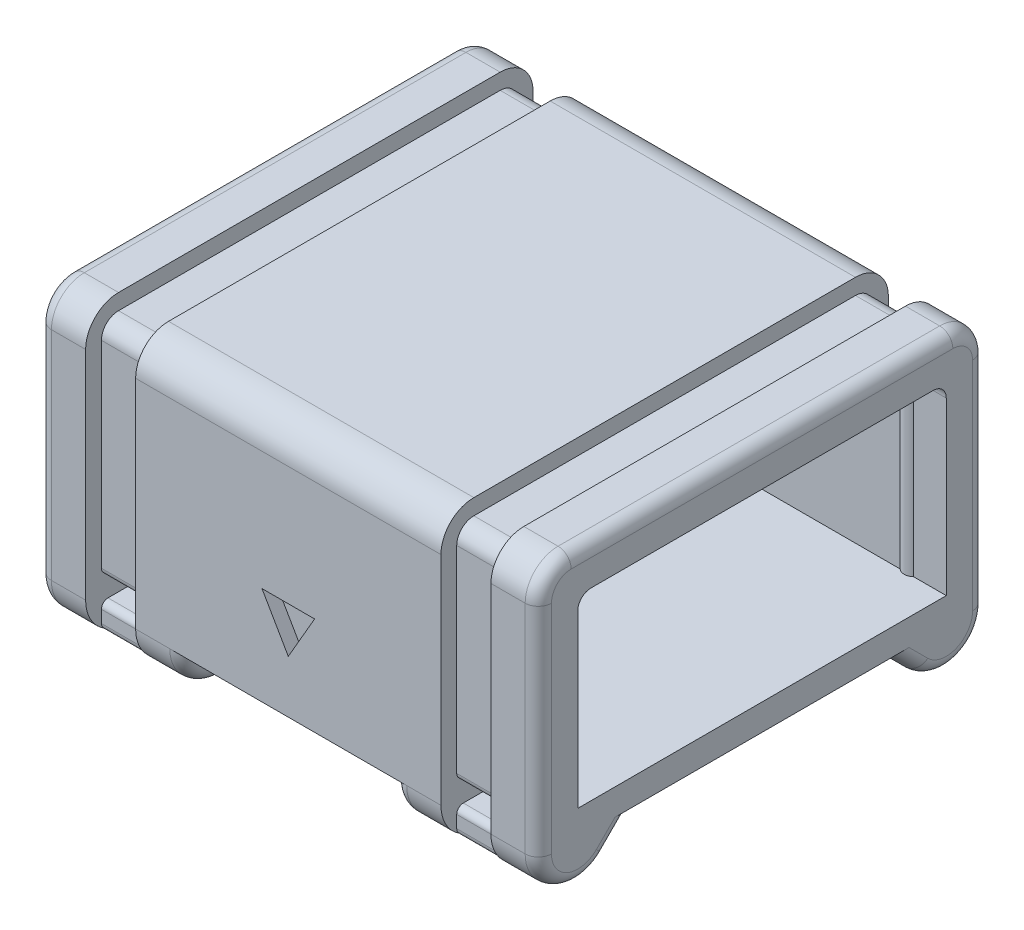
from build123d import *

# Parameters (mm, degrees)
AUFSATZ_LINEAR_AUSTRAGEN2_DEPTH           = 19
SCHNITT_LINEAR_AUSTRAGEN3_DEPTH           = 17
AUFSATZ_LINEAR_AUSTRAGEN9_DEPTH           = 38
SKIZZE14_W                                = 28
SKIZZE14_H                                = 9
AUFSATZ_LINEAR_AUSTRAGEN8_DEPTH           = 2
SCHNITT_LINEAR_AUSTRAGEN5_DEPTH           = 2
AUFSATZ_LINEAR_AUSTRAGEN10_DEPTH          = 14
SKIZZE20_R                                = 1.5
SCHNITT_LINEAR_AUSTRAGEN7_DEPTH           = 37.0000001
SCHNITT_LINEAR_AUSTRAGEN7_DEPTH_BACK      = 3
LINEARES_MUSTER1_COUNT                    = 2
LINEARES_MUSTER1_PITCH                    = 24
SKIZZE21_W                                = 16
SKIZZE21_H                                = 3
SCHNITT_LINEAR_AUSTRAGEN9_DEPTH           = 18
SCHNITT_LINEAR_AUSTRAGEN9_DEPTH_BACK      = 18
SKIZZE10_W                                = 10
SKIZZE10_H                                = 1.5
SKIZZE10_W_2                              = 7
SCHNITT_LINEAR_AUSTRAGEN8_DEPTH           = 1
SCHNITT_LINEAR_AUSTRAGEN10_DEPTH          = 1
SCHNITT_LINEAR_AUSTRAGEN11_DEPTH          = 1
VERRUNDUNG1_R                             = 1
VERRUNDUNG4_R                             = 1
SCHNITT_LINEAR_AUSTRAGEN_D_NN1_DEPTH      = 1.9
SCHNITT_LINEAR_AUSTRAGEN_D_NN1_DEPTH_BACK = 1.9
SCHNITT_LINEAR_AUSTRAGEN_D_NN2_DEPTH      = 1.9
SCHNITT_LINEAR_AUSTRAGEN_D_NN2_DEPTH_BACK = 1.9
SKIZZE26_W                                = 2
SKIZZE26_H                                = 8.3
AUFSATZ_LINEAR_AUSTRAGEN11_DEPTH          = 2
SKIZZE27_W                                = 3.8
SKIZZE27_H                                = 1.7
SCHNITT_LINEAR_AUSTRAGEN13_DEPTH          = 18
SCHNITT_LINEAR_AUSTRAGEN13_DEPTH_BACK     = 18.0000001
VERRUNDUNG5_R                             = 0.5
SCHNITT_LINEAR_AUSTRAGEN14_DEPTH          = 1


with BuildPart() as part:
    # Skizze2 → Aufsatz-Linear austragen2 (new body, symmetric)
    with BuildSketch(Plane(origin=(0, 0, 0), x_dir=(0, 0, -1), z_dir=(1, 0, 0))):
        with BuildLine():
            Line((-14, 9), (14, 9))
            Line((14, 9), (14, 0))
            Line((14, 0), (17, 0))
            Line((17, 0), (17, 14.5))
            ThreePointArc((17, 14.5), (16.267766953, 16.267766953), (14.5, 17))
            Line((14.5, 17), (-14.5, 17))
            ThreePointArc((-14.5, 17), (-16.267766953, 16.267766953), (-17, 14.5))
            Line((-17, 14.5), (-17, 0))
            Line((-17, 0), (-14, 0))
            Line((-14, 0), (-14, 9))
        make_face()
    extrude(amount=AUFSATZ_LINEAR_AUSTRAGEN2_DEPTH, both=True)

    # Skizze8 → Schnitt-Linear austragen3 (cut, symmetric)
    with BuildSketch(Plane(origin=(0, 0, 0), x_dir=(0, 0, -1), z_dir=(1, 0, 0))):
        with BuildLine():
            Line((-14, 9), (14, 9))
            Line((14, 9), (14, 13))
            ThreePointArc((14, 13), (13.707106781, 13.707106781), (13, 14))
            Line((13, 14), (-13, 14))
            ThreePointArc((-13, 14), (-13.707106781, 13.707106781), (-14, 13))
            Line((-14, 13), (-14, 9))
        make_face()
    extrude(amount=SCHNITT_LINEAR_AUSTRAGEN3_DEPTH, both=True, mode=Mode.SUBTRACT)

    # Skizze17 → Aufsatz-Linear austragen9 (add)
    with BuildSketch(Plane.ZY.offset(19)):
        with BuildLine():
            Line((-17, 0), (17, 0))
            Line((17, 0), (17, -2))
            ThreePointArc((17, -2), (15.148050297, -4.771638598), (11.878679656, -4.121320344))
            Line((11.878679656, -4.121320344), (9.757359313, -2))
            Line((9.757359313, -2), (-9.757359313, -2))
            Line((-9.757359313, -2), (-11.878679656, -4.121320344))
            ThreePointArc((-11.878679656, -4.121320344), (-15.148050297, -4.771638598), (-17, -2))
            Line((-17, -2), (-17, 0))
        make_face()
    extrude(amount=-AUFSATZ_LINEAR_AUSTRAGEN9_DEPTH)

    # Skizze14 → Aufsatz-Linear austragen8 (add)
    with BuildSketch(Plane.ZY.offset(19)):
        with Locations((0, 4.5)):
            Rectangle(SKIZZE14_W, SKIZZE14_H)
    extrude(amount=-AUFSATZ_LINEAR_AUSTRAGEN8_DEPTH)

    # Skizze12 → Schnitt-Linear austragen5 (cut)
    with BuildSketch(Plane(origin=(19, 0, 0), x_dir=(0, 0, -1), z_dir=(1, 0, 0))):
        with BuildLine():
            Line((-14, 9), (14, 9))
            Line((14, 9), (14, 13))
            ThreePointArc((14, 13), (13.707106781, 13.707106781), (13, 14))
            Line((13, 14), (-13, 14))
            ThreePointArc((-13, 14), (-13.707106781, 13.707106781), (-14, 13))
            Line((-14, 13), (-14, 9))
        make_face()
    extrude(amount=-SCHNITT_LINEAR_AUSTRAGEN5_DEPTH, mode=Mode.SUBTRACT)

    # Skizze19 → Aufsatz-Linear austragen10 (add)
    with BuildSketch(Plane(origin=(0, 14, 0), x_dir=(1, 0, 0), z_dir=(0, 1, 0))):
        with BuildLine():
            Line((15.5, 14), (16.5, 14))
            ThreePointArc((16.5, 14), (16, 13.8), (15.5, 14))
        make_face()
        with BuildLine():
            Line((15.5, -14), (16.5, -14))
            ThreePointArc((16.5, -14), (16, -13.8), (15.5, -14))
        make_face()
    aufsatz_linear_austragen10 = extrude(amount=-AUFSATZ_LINEAR_AUSTRAGEN10_DEPTH)

    # Skizze20 → Schnitt-Linear austragen7 (cut, two sides)
    with BuildSketch(Plane(origin=(-17, 0, 0), x_dir=(0, 0, -1), z_dir=(1, 0, 0))) as schnitt_linear_austragen7_sk:
        with Locations((0, 2)):
            Circle(SKIZZE20_R)
    extrude(amount=SCHNITT_LINEAR_AUSTRAGEN7_DEPTH, mode=Mode.SUBTRACT)
    extrude(schnitt_linear_austragen7_sk.sketch, amount=-SCHNITT_LINEAR_AUSTRAGEN7_DEPTH_BACK, mode=Mode.SUBTRACT)

    # Lineares Muster1: Aufsatz-Linear austragen10 ×2
    with Locations(*[(-i * LINEARES_MUSTER1_PITCH, 0, 0) for i in range(1, LINEARES_MUSTER1_COUNT)]):
        add(aufsatz_linear_austragen10)

    # Skizze21 → Schnitt-Linear austragen9 (cut, two sides)
    with BuildSketch(Plane.XY) as schnitt_linear_austragen9_sk:
        with Locations((0, -3.5)):
            Rectangle(SKIZZE21_W, SKIZZE21_H)
    extrude(amount=SCHNITT_LINEAR_AUSTRAGEN9_DEPTH, mode=Mode.SUBTRACT)
    extrude(schnitt_linear_austragen9_sk.sketch, amount=-SCHNITT_LINEAR_AUSTRAGEN9_DEPTH_BACK, mode=Mode.SUBTRACT)

    # Skizze10 → Schnitt-Linear austragen8 (cut)
    with BuildSketch(Plane(origin=(-19, -2, 0), x_dir=(0, -1, 0), z_dir=(1, 0, 0))):
        with Locations((-12, 0)):
            Rectangle(SKIZZE10_W, SKIZZE10_H)
        with Locations((-10.5, -9.9)):
            Rectangle(SKIZZE10_W_2, SKIZZE10_H)
        with Locations((-10.5, -6.6)):
            Rectangle(SKIZZE10_W_2, SKIZZE10_H)
        with Locations((-10.5, -3.3)):
            Rectangle(SKIZZE10_W_2, SKIZZE10_H)
        with Locations((-10.5, 3.3)):
            Rectangle(SKIZZE10_W_2, SKIZZE10_H)
        with Locations((-10.5, 6.6)):
            Rectangle(SKIZZE10_W_2, SKIZZE10_H)
        with Locations((-12, 9.9)):
            Rectangle(SKIZZE10_W, SKIZZE10_H)
    extrude(amount=SCHNITT_LINEAR_AUSTRAGEN8_DEPTH, mode=Mode.SUBTRACT)

    # Skizze5 → Schnitt-Linear austragen10 (cut)
    with BuildSketch(Plane.XY.offset(-17)):
        Polygon((0, 2), (-2, 5.464101615), (2, 5.464101615), align=None)
    extrude(amount=SCHNITT_LINEAR_AUSTRAGEN10_DEPTH, mode=Mode.SUBTRACT)

    # Skizze9 → Schnitt-Linear austragen11 (cut)
    with BuildSketch(Plane(origin=(0, 0, 17), x_dir=(-1, 0, 0), z_dir=(0, 0, -1))):
        Polygon((0, 2), (-2, 5.464101615), (2, 5.464101615), align=None)
    extrude(amount=SCHNITT_LINEAR_AUSTRAGEN11_DEPTH, mode=Mode.SUBTRACT)

    # Verrundung1
    verrundung1_edges = [part.edges().sort_by_distance(p)[0] for p in [
        (-19, 6.25, 17),
        (-19, 16.267766953, 16.267766953),
        (-19, 17, 0),
        (-19, 16.267766953, -16.267766953),
        (19, 6.25, -17),
        (-19, 6.25, -17),
        (19, 16.267766953, -16.267766953),
        (19, 17, 0),
        (19, 16.267766953, 16.267766953),
        (19, 6.25, 17),
        (-19, -4.771638598, -15.148050297),
        (-19, -3.060660172, -10.818019485),
        (-19, -3.060660172, 10.818019485),
        (-19, -4.771638598, 15.148050297),
        (19, -4.771638598, -15.148050297),
        (19, -3.060660172, -10.818019485),
        (19, -3.060660172, 10.818019485),
        (19, -4.771638598, 15.148050297),
    ]]
    fillet(verrundung1_edges, radius=VERRUNDUNG1_R)

    # Verrundung4
    verrundung4_edges = [part.edges().sort_by_distance(p)[0] for p in [
        (8, -4.771638598, 15.148050297),
        (-8, -4.771638598, 15.148050297),
        (-8, -4.771638598, -15.148050297),
        (-8, -3.060660172, -10.818019485),
        (-8, -3.060660172, 10.818019485),
        (8, -4.771638598, -15.148050297),
        (8, -3.060660172, -10.818019485),
        (8, -3.060660172, 10.818019485),
    ]]
    fillet(verrundung4_edges, radius=VERRUNDUNG4_R)

    # Skizze24 → Schnitt-Linear-Austragen-Dünn1 (cut, two sides)
    with BuildSketch(Plane(origin=(13.5, 0, 0), x_dir=(0, 0, -1), z_dir=(1, 0, 0))) as schnitt_linear_austragen_d_nn1_sk:
        with BuildLine():
            Line((-17, -5), (-17, 14.5))
            ThreePointArc((-17, 14.5), (-16.267766953, 16.267766953), (-14.5, 17))
            Line((-14.5, 17), (14.5, 17))
            ThreePointArc((14.5, 17), (16.267766953, 16.267766953), (17, 14.5))
            Line((17, 14.5), (17, -5))
            Line((17, -5), (15.8, -5))
            Line((15.8, -5), (15.8, 14.5))
            ThreePointArc((15.8, 14.5), (15.419238816, 15.419238816), (14.5, 15.8))
            Line((14.5, 15.8), (-14.5, 15.8))
            ThreePointArc((-14.5, 15.8), (-15.419238816, 15.419238816), (-15.8, 14.5))
            Line((-15.8, 14.5), (-15.8, -5))
            Line((-15.8, -5), (-17, -5))
        make_face()
    extrude(amount=SCHNITT_LINEAR_AUSTRAGEN_D_NN1_DEPTH, mode=Mode.SUBTRACT)
    extrude(schnitt_linear_austragen_d_nn1_sk.sketch, amount=-SCHNITT_LINEAR_AUSTRAGEN_D_NN1_DEPTH_BACK, mode=Mode.SUBTRACT)

    # Skizze25 → Schnitt-Linear-Austragen-Dünn2 (cut, two sides)
    with BuildSketch(Plane(origin=(-13.5, 0, 0), x_dir=(0, 0, -1), z_dir=(1, 0, 0))) as schnitt_linear_austragen_d_nn2_sk:
        with BuildLine():
            Line((-17, -5), (-17, 14.5))
            ThreePointArc((-17, 14.5), (-16.267766953, 16.267766953), (-14.5, 17))
            Line((-14.5, 17), (14.5, 17))
            ThreePointArc((14.5, 17), (16.267766953, 16.267766953), (17, 14.5))
            Line((17, 14.5), (17, -5))
            Line((17, -5), (15.8, -5))
            Line((15.8, -5), (15.8, 14.5))
            ThreePointArc((15.8, 14.5), (15.419238816, 15.419238816), (14.5, 15.8))
            Line((14.5, 15.8), (-14.5, 15.8))
            ThreePointArc((-14.5, 15.8), (-15.419238816, 15.419238816), (-15.8, 14.5))
            Line((-15.8, 14.5), (-15.8, -5))
            Line((-15.8, -5), (-17, -5))
        make_face()
    extrude(amount=SCHNITT_LINEAR_AUSTRAGEN_D_NN2_DEPTH, mode=Mode.SUBTRACT)
    extrude(schnitt_linear_austragen_d_nn2_sk.sketch, amount=-SCHNITT_LINEAR_AUSTRAGEN_D_NN2_DEPTH_BACK, mode=Mode.SUBTRACT)

    # Skizze26 → Aufsatz-Linear austragen11 (add)
    with BuildSketch(Plane(origin=(-17, 0, 0), x_dir=(0, 0, -1), z_dir=(1, 0, 0))):
        with Locations((-13, 9.85)):
            Rectangle(SKIZZE26_W, SKIZZE26_H)
        with Locations((13, 9.85)):
            Rectangle(SKIZZE26_W, SKIZZE26_H)
    extrude(amount=AUFSATZ_LINEAR_AUSTRAGEN11_DEPTH)

    # Skizze27 → Schnitt-Linear austragen13 (cut, two sides)
    with BuildSketch(Plane.XY) as schnitt_linear_austragen13_sk:
        with Locations((13.5, -1.85)):
            Rectangle(SKIZZE27_W, SKIZZE27_H)
        with Locations((-13.5, -1.85)):
            Rectangle(SKIZZE27_W, SKIZZE27_H)
    extrude(amount=SCHNITT_LINEAR_AUSTRAGEN13_DEPTH, mode=Mode.SUBTRACT)
    extrude(schnitt_linear_austragen13_sk.sketch, amount=-SCHNITT_LINEAR_AUSTRAGEN13_DEPTH_BACK, mode=Mode.SUBTRACT)

    # Verrundung5
    verrundung5_edges = [part.edges().sort_by_distance(p)[0] for p in [
        (13.5, -4.4, 15.8),
        (13.5, -4.4, -15.8),
        (-13.5, -4.4, 15.8),
        (-13.5, -4.4, -15.8),
        (13.5, -2.7, -10.457359313),
        (13.5, -2.7, 10.457359313),
        (13.5, -2.7, -15.8),
        (13.5, -2.7, 15.8),
        (13.5, -1, -15.8),
        (13.5, -1, 15.8),
        (-13.5, -1, -15.8),
        (-13.5, -1, 15.8),
        (-13.5, -2.7, -10.457359313),
        (-13.5, -2.7, 10.457359313),
        (-13.5, -2.7, -15.8),
        (-13.5, -2.7, 15.8),
    ]]
    fillet(verrundung5_edges, radius=VERRUNDUNG5_R)

    # Skizze28 → Schnitt-Linear austragen14 (cut)
    with BuildSketch(Plane.ZY.offset(19)):
        with BuildLine():
            Line((10.914882249, 0.5), (10.914882249, 4.095646159))
            Line((10.914882249, 4.095646159), (12.475012373, 4.095646159))
            add(Edge.make_bspline(
                [(12.475012373, 4.095646159), (12.511748661, 4.095358315), (12.582847445, 4.094801226), (12.685955363, 4.090857673), (12.782196267, 4.082356407), (12.871747113, 4.073163473), (12.954591991, 4.059053546), (13.030645431, 4.042869779), (13.100024856, 4.023610851), (13.163040434, 4.000864573), (13.22150515, 3.975130567), (13.275697525, 3.943378959), (13.327870267, 3.908585966), (13.376087064, 3.867709392), (13.421619637, 3.822953326), (13.464425787, 3.77370963), (13.503871802, 3.719550968), (13.552523737, 3.64203869), (13.604717344, 3.538808659), (13.648202817, 3.406696588), (13.676241472, 3.268502539), (13.679241688, 3.174062915), (13.68076391, 3.126147014)],
                knots=[0, 0, 0, 0, 0.000110213, 0.000213303, 0.000309428, 0.000400026, 0.000483271, 0.000561397, 0.000633227, 0.000699073, 0.000762261, 0.000824531, 0.000887262, 0.000950158, 0.001013824, 0.001078669, 0.00114566, 0.001214604, 0.001353115, 0.001491374, 0.001630798, 0.001774394, 0.001774394, 0.001774394, 0.001774394], degree=3))
            add(Edge.make_bspline(
                [(13.68076391, 3.126147014), (13.680060304, 3.095389279), (13.678670635, 3.034640643), (13.66802563, 2.945323887), (13.648764353, 2.859985319), (13.624065562, 2.777877558), (13.590260452, 2.70016394), (13.551098699, 2.625257141), (13.502582854, 2.55521505), (13.448264002, 2.488172559), (13.385974844, 2.425565539), (13.315167425, 2.369652697), (13.236543643, 2.319358984), (13.14973321, 2.276072023), (13.055735403, 2.236505685), (12.953370806, 2.204644964), (12.843052556, 2.178628241), (12.766574817, 2.166029941), (12.727110962, 2.159528996)],
                knots=[0, 0, 0, 0, 9.2266e-05, 0.000182232, 0.000269264, 0.000354471, 0.000439024, 0.000523127, 0.000607634, 0.000694142, 0.000781745, 0.000871961, 0.000964273, 0.001061233, 0.001162626, 0.001269919, 0.001382431, 0.00150239, 0.00150239, 0.00150239, 0.00150239], degree=3))
            add(Edge.make_bspline(
                [(12.727110962, 2.159528996), (12.756059194, 2.144904988), (12.81103293, 2.11713347), (12.887144747, 2.07358797), (12.9516621, 2.0290952), (12.989040272, 1.997272663), (13.006580255, 1.982339703)],
                knots=[0, 0, 0, 0, 9.7289e-05, 0.000184755, 0.000262881, 0.000331957, 0.000331957, 0.000331957, 0.000331957], degree=3))
            add(Edge.make_bspline(
                [(13.006580255, 1.982339703), (13.040547422, 1.949041952), (13.110318397, 1.880646008), (13.206465831, 1.764147678), (13.29968407, 1.634467161), (13.356321178, 1.540746612), (13.38544842, 1.492548158)],
                knots=[0, 0, 0, 0, 0.000142612, 0.000292935, 0.000452443, 0.000621329, 0.000621329, 0.000621329, 0.000621329], degree=3))
            Line((13.38544842, 1.492548158), (13.975359118, 0.5))
            Line((13.975359118, 0.5), (13.3940918, 0.5))
            Line((13.3940918, 0.5), (12.946076594, 1.259176893))
            add(Edge.make_bspline(
                [(12.946076594, 1.259176893), (12.929968217, 1.285813527), (12.898752829, 1.33743095), (12.853663318, 1.412815711), (12.809454535, 1.482219394), (12.768451646, 1.547625596), (12.728990683, 1.607846898), (12.691452932, 1.663092498), (12.65687145, 1.714087145), (12.614037812, 1.773458186), (12.564186573, 1.839152793), (12.506013597, 1.906805833), (12.450615676, 1.960744701), (12.382392114, 2.013637498), (12.297886911, 2.063109819), (12.226055893, 2.085840992), (12.19122139, 2.09686449)],
                knots=[0, 0, 0, 0, 9.3387e-05, 0.000180969, 0.000263503, 0.000340236, 0.000412555, 0.000479479, 0.000540614, 0.000597384, 0.000699094, 0.000787926, 0.000864848, 0.000930548, 0.001046689, 0.001156044, 0.001156044, 0.001156044, 0.001156044], degree=3))
            add(Edge.make_bspline(
                [(12.19122139, 2.09686449), (12.176606124, 2.099500119), (12.143239034, 2.10551734), (12.086581797, 2.109447196), (12.017934604, 2.113618213), (11.968184813, 2.113496683), (11.941283647, 2.113430969)],
                knots=[0, 0, 0, 0, 4.4524e-05, 0.000101649, 0.00017017, 0.000250845, 0.000250845, 0.000250845, 0.000250845], degree=3))
            Line((11.941283647, 2.113430969), (11.421960554, 2.113430969))
            Line((11.421960554, 2.113430969), (11.421960554, 0.5))
            Line((11.421960554, 0.5), (10.914882249, 0.5))
        make_face()
        with BuildLine():
            Line((11.421960554, 2.528313218), (12.384977163, 2.528313218))
            add(Edge.make_bspline(
                [(12.384977163, 2.528313218), (12.433266464, 2.52906875), (12.523538782, 2.530481146), (12.649770338, 2.542541523), (12.75734771, 2.561705975), (12.84839755, 2.589659573), (12.924893787, 2.62846845), (12.991424018, 2.675764318), (13.046711477, 2.735007316), (13.092704932, 2.801850427), (13.128456588, 2.875407934), (13.154246128, 2.95266931), (13.17112583, 3.032985223), (13.17282479, 3.087647122), (13.173685605, 3.115342789)],
                knots=[0, 0, 0, 0, 0.000144841, 0.000270767, 0.000379967, 0.000472222, 0.00055533, 0.0006363, 0.000715779, 0.000797095, 0.000878916, 0.000960231, 0.001041031, 0.001124017, 0.001124017, 0.001124017, 0.001124017], degree=3))
            add(Edge.make_bspline(
                [(13.173685605, 3.115342789), (13.173016357, 3.135525674), (13.171705496, 3.175058018), (13.16483353, 3.233080523), (13.151472796, 3.288215314), (13.13382998, 3.340753839), (13.110255598, 3.390311293), (13.082250193, 3.437271689), (13.0488311, 3.481374756), (13.010551451, 3.522754837), (12.966599458, 3.560406666), (12.916395949, 3.592892029), (12.860336877, 3.620497579), (12.798357081, 3.642407189), (12.730651809, 3.65993131), (12.656835631, 3.671589543), (12.577246123, 3.680025401), (12.522095209, 3.680513141), (12.493739697, 3.68076391)],
                knots=[0, 0, 0, 0, 6.0572e-05, 0.000118643, 0.000174899, 0.000230477, 0.000284609, 0.000339208, 0.000394238, 0.0004503, 0.000508034, 0.000567369, 0.000629217, 0.000695063, 0.000764244, 0.000838726, 0.000919069, 0.001004089, 0.001004089, 0.001004089, 0.001004089], degree=3))
            Line((12.493739697, 3.68076391), (11.421960554, 3.68076391))
            Line((11.421960554, 3.68076391), (11.421960554, 2.528313218))
        make_face(mode=Mode.SUBTRACT)
    extrude(amount=-SCHNITT_LINEAR_AUSTRAGEN14_DEPTH, mode=Mode.SUBTRACT)


solid = part.part
